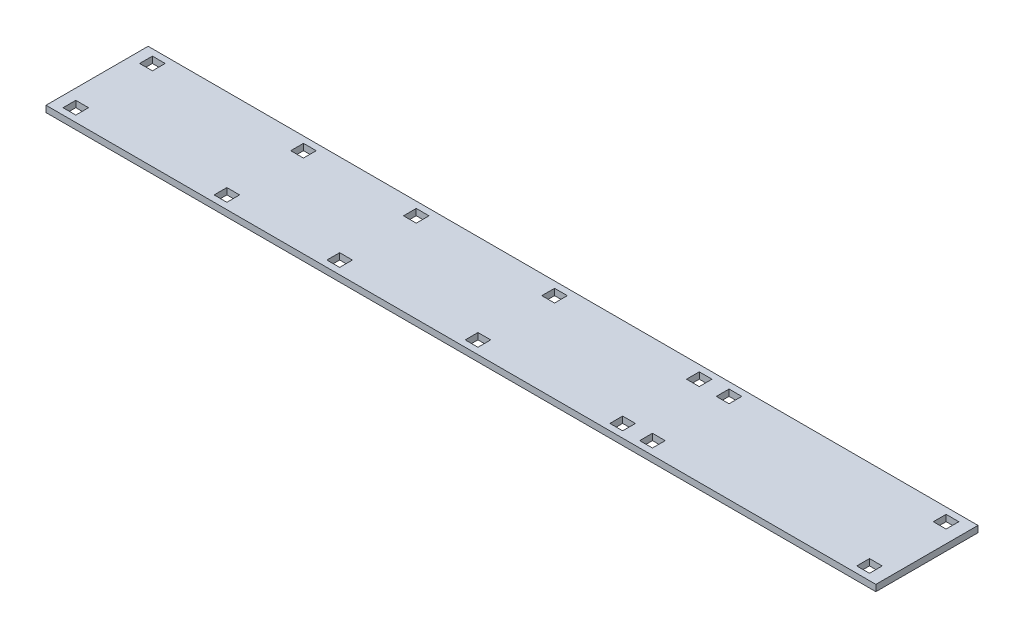
from build123d import *

# Parameters (mm, degrees)
SKETCH1_W           = 195
SKETCH1_H           = 24
SKETCH1_W_2         = 3
SKETCH1_H_2         = 3
BOSS_EXTRUDE1_DEPTH = 1.5


with BuildPart() as part:
    # Sketch1 → Boss-Extrude1 (new body)
    with BuildSketch(Plane(origin=(0, 0, 0), x_dir=(1, 0, 0), z_dir=(0, 1, 0))):
        with Locations((97.5, 12)):
            Rectangle(SKETCH1_W, SKETCH1_H)
        with Locations((66, 3)):
            Rectangle(SKETCH1_W_2, SKETCH1_H_2, mode=Mode.SUBTRACT)
        with Locations((4, 21)):
            Rectangle(SKETCH1_W_2, SKETCH1_H_2, mode=Mode.SUBTRACT)
        with Locations((39.5, 3)):
            Rectangle(SKETCH1_W_2, SKETCH1_H_2, mode=Mode.SUBTRACT)
        with Locations((98.5, 3)):
            Rectangle(SKETCH1_W_2, SKETCH1_H_2, mode=Mode.SUBTRACT)
        with Locations((139.5, 3)):
            Rectangle(SKETCH1_W_2, SKETCH1_H_2, mode=Mode.SUBTRACT)
        with Locations((139.5, 21)):
            Rectangle(SKETCH1_W_2, SKETCH1_H_2, mode=Mode.SUBTRACT)
        with Locations((132.5, 3)):
            Rectangle(SKETCH1_W_2, SKETCH1_H_2, mode=Mode.SUBTRACT)
        with Locations((132.5, 21)):
            Rectangle(SKETCH1_W_2, SKETCH1_H_2, mode=Mode.SUBTRACT)
        with Locations((66, 21)):
            Rectangle(SKETCH1_W_2, SKETCH1_H_2, mode=Mode.SUBTRACT)
        with Locations((98.5, 21)):
            Rectangle(SKETCH1_W_2, SKETCH1_H_2, mode=Mode.SUBTRACT)
        with Locations((39.5, 21)):
            Rectangle(SKETCH1_W_2, SKETCH1_H_2, mode=Mode.SUBTRACT)
        with Locations((4, 3)):
            Rectangle(SKETCH1_W_2, SKETCH1_H_2, mode=Mode.SUBTRACT)
        with Locations((190.5, 21)):
            Rectangle(SKETCH1_W_2, SKETCH1_H_2, mode=Mode.SUBTRACT)
        with Locations((190.5, 3)):
            Rectangle(SKETCH1_W_2, SKETCH1_H_2, mode=Mode.SUBTRACT)
    extrude(amount=BOSS_EXTRUDE1_DEPTH)


solid = part.part
